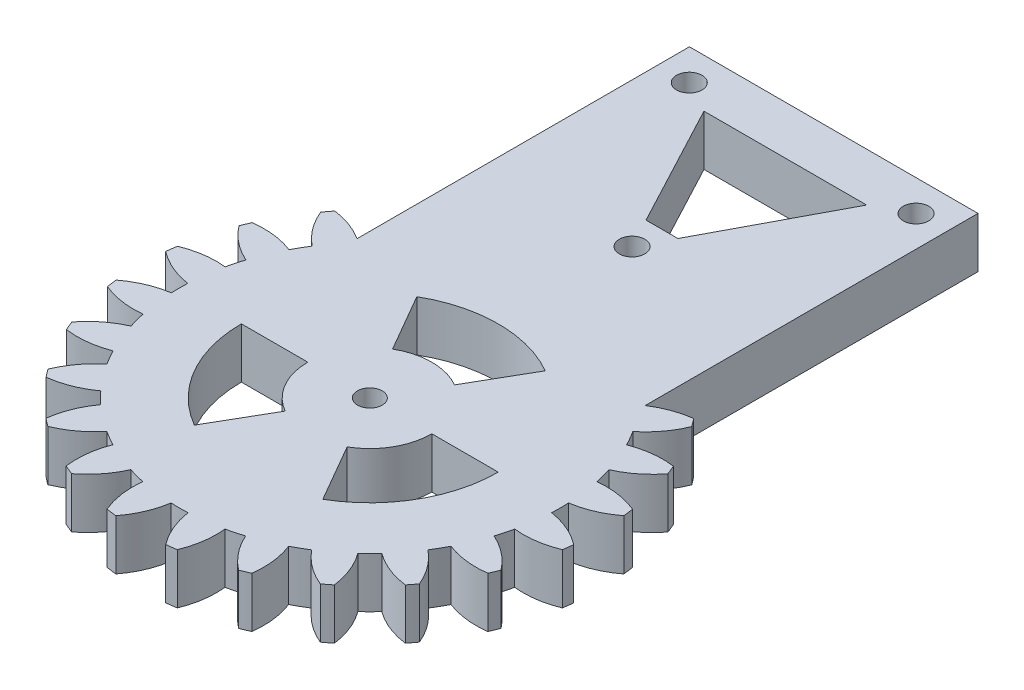
from build123d import *

# Parameters (mm, degrees)
SKETCH1_R           = 1.4
SKETCH1_R_2         = 1.44
BOSS_EXTRUDE2_DEPTH = 5.7


with BuildPart() as part:
    # Sketch1 → Boss-Extrude2 (new body)
    with BuildSketch(Plane(origin=(0, 0, 0), x_dir=(1, 0, 0), z_dir=(0, 1, 0))):
        with BuildLine():
            Line((16.282643734, -55.473929669), (-16.294749294, -55.473929669))
            Line((-16.294749294, -55.473929669), (-16.294749294, -92.997636196))
            ThreePointArc((-16.294749294, -92.997636196), (-18.191440049, -92.050885637), (-20.249670305, -91.543479832))
            ThreePointArc((-20.249670305, -91.543479832), (-20.602163218, -91.991288827), (-20.944755668, -92.446716717))
            ThreePointArc((-20.944755668, -92.446716717), (-19.764567011, -94.531247615), (-18.105041425, -96.258699254))
            ThreePointArc((-18.105041425, -96.258699254), (-18.601337045, -97.073436545), (-19.060996376, -97.909390787))
            ThreePointArc((-19.060996376, -97.909390787), (-21.385246964, -97.329758545), (-23.780643137, -97.343597276))
            ThreePointArc((-23.780643137, -97.343597276), (-24.005836083, -97.869056559), (-24.219420722, -98.399340372))
            ThreePointArc((-24.219420722, -98.399340372), (-22.53946113, -100.106926418), (-20.489045224, -101.345437195))
            ThreePointArc((-20.489045224, -101.345437195), (-20.758075202, -102.263784688), (-20.985968299, -103.193195246))
            ThreePointArc((-20.985968299, -103.193195246), (-23.3810186, -103.236188129), (-25.690864, -103.870797115))
            ThreePointArc((-25.690864, -103.870797115), (-25.775064405, -104.459357336), (-25.845783772, -105.049689119))
            ThreePointArc((-25.845783772, -105.049689119), (-23.779779823, -106.262018289), (-21.477950818, -106.92511524))
            ThreePointArc((-21.477950818, -106.92511524), (-21.497710797, -107.846662377), (-21.477950818, -108.768209514))
            ThreePointArc((-21.477950818, -108.768209514), (-23.780746321, -109.427942192), (-25.848519588, -110.637251105))
            ThreePointArc((-25.848519588, -110.637251105), (-25.781205181, -111.202699229), (-25.701523459, -111.766537533))
            ThreePointArc((-25.701523459, -111.766537533), (-23.393073925, -112.406205481), (-20.998123562, -112.454445414))
            ThreePointArc((-20.998123562, -112.454445414), (-20.773235617, -113.38074943), (-20.507508787, -114.296174451))
            ThreePointArc((-20.507508787, -114.296174451), (-22.561079267, -115.529447584), (-24.245391936, -117.232740033))
            ThreePointArc((-24.245391936, -117.232740033), (-24.033987825, -117.761573279), (-23.811051179, -118.285649183))
            ThreePointArc((-23.811051179, -118.285649183), (-21.415701651, -118.306020019), (-19.089879068, -117.732728078))
            ThreePointArc((-19.089879068, -117.732728078), (-18.6328306, -118.56937566), (-18.139140457, -119.384938363))
            ThreePointArc((-18.139140457, -119.384938363), (-19.803499131, -121.107733922), (-20.989523145, -123.188950243))
            ThreePointArc((-20.989523145, -123.188950243), (-20.6482393, -123.645300692), (-20.297036031, -124.094061943))
            ThreePointArc((-20.297036031, -124.094061943), (-17.978064026, -123.493659436), (-15.879929184, -122.337828774))
            ThreePointArc((-15.879929184, -122.337828774), (-15.221495643, -123.028026694), (-14.533094291, -123.688338344))
            ThreePointArc((-14.533094291, -123.688338344), (-15.694637363, -125.783316155), (-16.301356047, -128.100643661))
            ThreePointArc((-16.301356047, -128.100643661), (-15.852512396, -128.453869244), (-15.396017905, -128.797150052))
            ThreePointArc((-15.396017905, -128.797150052), (-13.311697063, -127.616590454), (-11.584540779, -125.95675748))
            ThreePointArc((-11.584540779, -125.95675748), (-10.767926313, -126.453945848), (-9.930014765, -126.914336658))
            ThreePointArc((-9.930014765, -126.914336658), (-10.50881973, -129.2387934), (-10.494128437, -131.634184496))
            ThreePointArc((-10.494128437, -131.634184496), (-9.96421413, -131.861006909), (-9.429401724, -132.076026145))
            ThreePointArc((-9.429401724, -132.076026145), (-7.723011964, -130.394851461), (-6.485961057, -128.34355446))
            ThreePointArc((-6.485961057, -128.34355446), (-5.571070397, -128.610954069), (-4.645226545, -128.837538785))
            ThreePointArc((-4.645226545, -128.837538785), (-4.607931078, -131.230595815), (-3.979841993, -133.540058306))
            ThreePointArc((-3.979841993, -133.540058306), (-3.404307437, -133.622657246), (-2.827069767, -133.692365802))
            ThreePointArc((-2.827069767, -133.692365802), (-1.614740596, -131.626361853), (-0.951643646, -129.324532848))
            ThreePointArc((-0.951643646, -129.324532848), (0.001289203, -129.345662377), (0.954222052, -129.324532848))
            ThreePointArc((0.954222052, -129.324532848), (1.605623598, -131.625984951), (2.805751963, -133.694969645))
            ThreePointArc((2.805751963, -133.694969645), (3.383053833, -133.62579479), (3.958664509, -133.543727981))
            ThreePointArc((3.958664509, -133.543727981), (4.594963395, -131.234347532), (4.63970868, -128.839329329))
            ThreePointArc((4.63970868, -128.839329329), (5.565639854, -128.613101716), (6.480633579, -128.346054989))
            ThreePointArc((6.480633579, -128.346054989), (7.716893233, -130.397828953), (9.422634458, -132.079661646))
            ThreePointArc((9.422634458, -132.079661646), (9.951058445, -131.867530222), (10.474710197, -131.643877606))
            ThreePointArc((10.474710197, -131.643877606), (10.491616082, -129.248501117), (9.914960384, -126.923510248))
            ThreePointArc((9.914960384, -126.923510248), (10.750789203, -126.465342533), (11.565488494, -125.9705774))
            ThreePointArc((11.565488494, -125.9705774), (13.290661801, -127.632471318), (15.373571634, -128.815518637))
            ThreePointArc((15.373571634, -128.815518637), (15.829086357, -128.473849224), (16.277009552, -128.12228634))
            ThreePointArc((16.277009552, -128.12228634), (15.673370328, -125.804154761), (14.514611779, -123.707635512))
            ThreePointArc((14.514611779, -123.707635512), (15.203377892, -123.048751065), (15.862262338, -122.359984953))
            ThreePointArc((15.862262338, -122.359984953), (17.958781587, -123.518743501), (20.276913167, -124.122382726))
            ThreePointArc((20.276913167, -124.122382726), (20.628476051, -123.674459531), (20.970145463, -123.218944808))
            ThreePointArc((20.970145463, -123.218944808), (19.787098144, -121.136034974), (18.125204226, -119.410861668))
            ThreePointArc((18.125204226, -119.410861668), (18.619969359, -118.596162377), (19.078137075, -117.760333557))
            ThreePointArc((19.078137075, -117.760333557), (21.403127944, -118.336989255), (23.798504433, -118.32008337))
            ThreePointArc((23.798504433, -118.32008337), (24.022157048, -117.796431618), (24.234288472, -117.268007632))
            ThreePointArc((24.234288472, -117.268007632), (22.552455779, -115.562266407), (20.500681815, -114.326006752))
            ThreePointArc((20.500681815, -114.326006752), (20.767728542, -113.411013027), (20.993956155, -112.485081853))
            ThreePointArc((20.993956155, -112.485081853), (23.388974358, -112.440336569), (25.698354808, -111.804037682))
            ThreePointArc((25.698354808, -111.804037682), (25.778855599, -111.240343374), (25.846992628, -110.675021347))
            ThreePointArc((25.846992628, -110.675021347), (23.780988679, -109.462692176), (21.479159674, -108.799595225))
            ThreePointArc((21.479159674, -108.799595225), (21.500289203, -107.846662377), (21.479159674, -106.893729528))
            ThreePointArc((21.479159674, -106.893729528), (23.780988679, -106.230632577), (25.846992628, -105.018303407))
            ThreePointArc((25.846992628, -105.018303407), (25.778855599, -104.452981379), (25.698354808, -103.889287071))
            ThreePointArc((25.698354808, -103.889287071), (23.388974358, -103.252988184), (20.993956155, -103.2082429))
            ThreePointArc((20.993956155, -103.2082429), (20.767728542, -102.282311726), (20.500681815, -101.367318001))
            ThreePointArc((20.500681815, -101.367318001), (22.552455779, -100.131058346), (24.234288472, -98.425317121))
            ThreePointArc((24.234288472, -98.425317121), (24.022157048, -97.896893135), (23.798504433, -97.373241383))
            ThreePointArc((23.798504433, -97.373241383), (21.403127944, -97.356335498), (19.078137075, -97.932991196))
            ThreePointArc((19.078137075, -97.932991196), (18.619969359, -97.097162377), (18.125204226, -96.282463086))
            ThreePointArc((18.125204226, -96.282463086), (19.787098144, -94.557289779), (20.970145463, -92.474379945))
            ThreePointArc((20.970145463, -92.474379945), (20.628476051, -92.018865222), (20.276913167, -91.570942027))
            ThreePointArc((20.276913167, -91.570942027), (18.197116907, -92.083089067), (16.282643734, -93.043630342))
            Line((16.282643734, -93.043630342), (16.282643734, -55.473929669))
        make_face()
        with BuildLine():
            ThreePointArc((-6.998710797, -107.846662377), (-6.060888623, -111.346662377), (-3.498710797, -113.908840203))
            Line((-3.498710797, -113.908840203), (-7.248210797, -120.403164706))
            ThreePointArc((-7.248210797, -120.403164706), (-12.555213127, -115.096162377), (-14.497710797, -107.846662377))
            Line((-14.497710797, -107.846662377), (-6.998710797, -107.846662377))
        make_face(mode=Mode.SUBTRACT)
        with Locations((0.001289203, -107.846662377)):
            Circle(SKETCH1_R, mode=Mode.SUBTRACT)
        with BuildLine():
            Line((7.250789203, -120.403164706), (3.501289203, -113.908840203))
            ThreePointArc((3.501289203, -113.908840203), (6.06346703, -111.346662377), (7.001289203, -107.846662377))
            Line((7.001289203, -107.846662377), (14.500289203, -107.846662377))
            ThreePointArc((14.500289203, -107.846662377), (12.557791533, -115.096162377), (7.250789203, -120.403164706))
        make_face(mode=Mode.SUBTRACT)
        with BuildLine():
            Line((7.250246793, -95.289846902), (3.501289203, -101.78448455))
            ThreePointArc((3.501289203, -101.78448455), (0.001289203, -100.846662377), (-3.498710797, -101.78448455))
            Line((-3.498710797, -101.78448455), (-7.248210797, -95.290160047))
            ThreePointArc((-7.248210797, -95.290160047), (0.000976046, -93.34766238), (7.250246793, -95.289846902))
        make_face(mode=Mode.SUBTRACT)
        with Locations((-12.8, -58.985750662)):
            Circle(SKETCH1_R_2, mode=Mode.SUBTRACT)
        with Locations((0, -78.242875331)):
            Circle(SKETCH1_R_2, mode=Mode.SUBTRACT)
        Polygon((-1.8, -74.867693206), (-9.18, -60.945750662), (9.18, -60.945750662), (1.8, -74.867693206), align=None, mode=Mode.SUBTRACT)
        with Locations((12.8, -58.985750662)):
            Circle(SKETCH1_R_2, mode=Mode.SUBTRACT)
    extrude(amount=BOSS_EXTRUDE2_DEPTH)


solid = part.part
